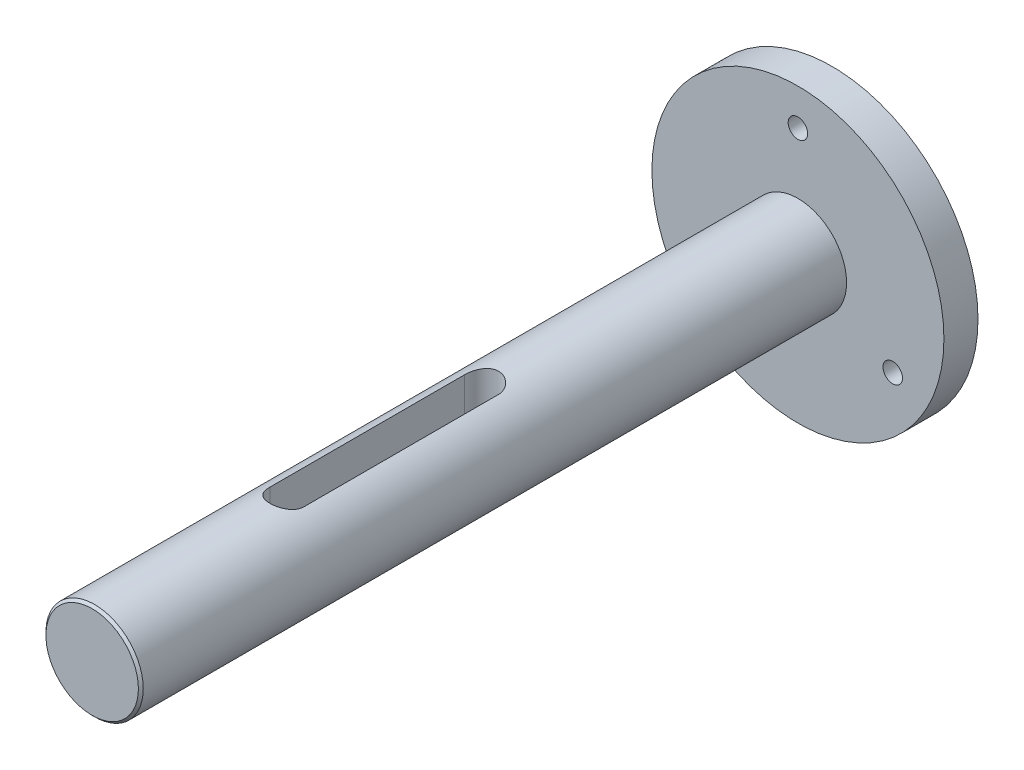
from build123d import *

# Parameters (mm, degrees)
SKETCH1_R               = 30
SKETCH1_R_2             = 2
BOSS_EXTRUDE1_DEPTH     = 7
SKETCH2_R               = 10
BOSS_EXTRUDE2_DEPTH     = 145
CUT_EXTRUDE1_DEPTH      = 25
CUT_EXTRUDE1_DEPTH_BACK = 1.5
CHAMFER2_SIZE           = 1.5
CUT_EXTRUDE2_DEPTH      = 25
CHAMFER1_SIZE           = 0.5


with BuildPart() as part:
    # Sketch1 → Boss-Extrude1 (new body)
    with BuildSketch(Plane.XY):
        Circle(SKETCH1_R)
        with Locations((0, 22.5)):
            Circle(SKETCH1_R_2, mode=Mode.SUBTRACT)
        with Locations((19.485571585, -11.25)):
            Circle(SKETCH1_R_2, mode=Mode.SUBTRACT)
        with Locations((-19.485571585, -11.25)):
            Circle(SKETCH1_R_2, mode=Mode.SUBTRACT)
    extrude(amount=BOSS_EXTRUDE1_DEPTH)

    # Sketch2 → Boss-Extrude2 (add)
    with BuildSketch(Plane.XY.offset(7)):
        Circle(SKETCH2_R)
    extrude(amount=BOSS_EXTRUDE2_DEPTH)

    # Sketch3 → Cut-Extrude1 (cut, two sides)
    with BuildSketch(Plane(origin=(0, 0, 0), x_dir=(1, 0, 0), z_dir=(0, 1, 0))) as cut_extrude1_sk:
        with BuildLine():
            Line((3.5, -72), (3.5, -112))
            ThreePointArc((3.5, -112), (0, -115.5), (-3.5, -112))
            Line((-3.5, -112), (-3.5, -72))
            ThreePointArc((-3.5, -72), (0, -68.5), (3.5, -72))
        make_face()
    extrude(amount=CUT_EXTRUDE1_DEPTH, mode=Mode.SUBTRACT)
    extrude(cut_extrude1_sk.sketch, amount=-CUT_EXTRUDE1_DEPTH_BACK, mode=Mode.SUBTRACT)

    # Chamfer2
    chamfer2_edges = [part.edges().sort_by_distance(p)[0] for p in [
        (0, -1.5, 68.5),
        (3.5, -1.5, 92),
        (0, -1.5, 115.5),
        (-3.5, -1.5, 92),
    ]]
    chamfer(chamfer2_edges, length=CHAMFER2_SIZE)

    # Sketch4 → Cut-Extrude2 (cut)
    with BuildSketch(Plane(origin=(0, 0, 0), x_dir=(1, 0, 0), z_dir=(0, 1, 0))):
        with BuildLine():
            Line((2, -72), (2, -112))
            ThreePointArc((2, -112), (0, -114), (-2, -112))
            Line((-2, -112), (-2, -72))
            ThreePointArc((-2, -72), (0, -70), (2, -72))
        make_face()
    extrude(amount=-CUT_EXTRUDE2_DEPTH, mode=Mode.SUBTRACT)

    # Chamfer1
    chamfer1_edges = [part.edges().sort_by_distance(p)[0] for p in [
        (-10, 0, 152),
    ]]
    chamfer(chamfer1_edges, length=CHAMFER1_SIZE)


solid = part.part
